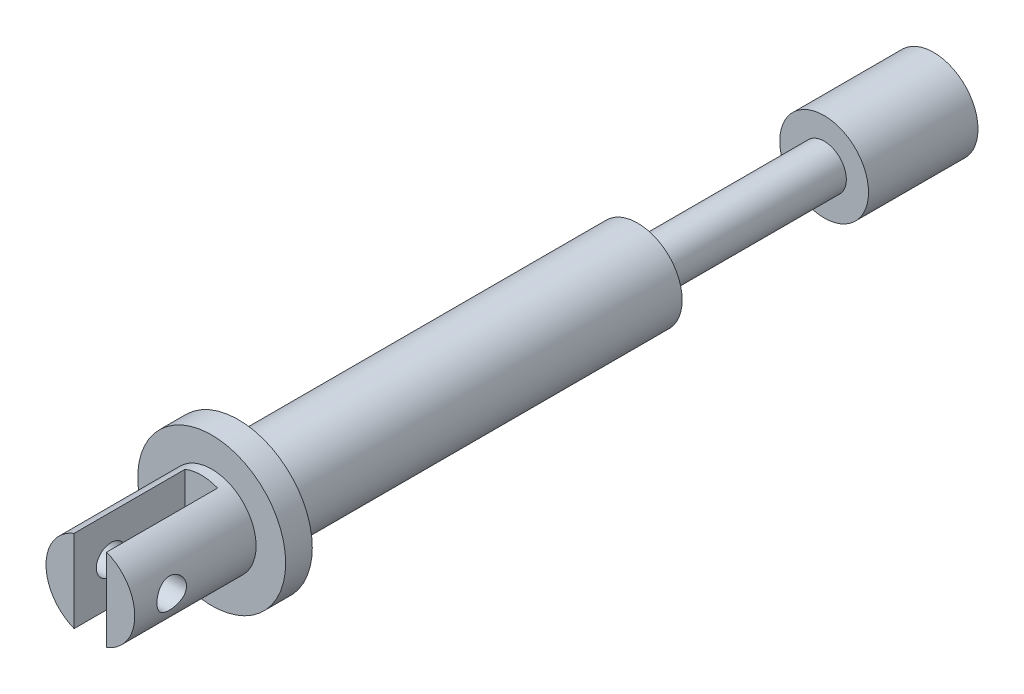
from build123d import *

# Parameters (mm, degrees)
SKETCH1_R               = 1.5
BOSS_EXTRUDE1_DEPTH     = 28.5
SKETCH2_R               = 3
BOSS_EXTRUDE2_DEPTH     = 37
SKETCH5_R               = 5
BOSS_EXTRUDE3_DEPTH     = 1.8
SKETCH6_R               = 3
BOSS_EXTRUDE4_DEPTH     = 7.4
SKETCH3_W               = 2.2
SKETCH3_H               = 7.5
CUT_EXTRUDE1_DEPTH      = 6
CUT_EXTRUDE1_DEPTH_BACK = 6
SKETCH4_R               = 1
CUT_EXTRUDE2_DEPTH      = 6
CUT_EXTRUDE2_DEPTH_BACK = 6


with BuildPart() as part:
    # Sketch1 → Boss-Extrude1 (new body, symmetric)
    with BuildSketch(Plane.XY):
        Circle(SKETCH1_R)
    extrude(amount=BOSS_EXTRUDE1_DEPTH, both=True)

    # Sketch2 → Boss-Extrude2 (add)
    with BuildSketch(Plane.XY.offset(28.5)):
        Circle(SKETCH2_R)
    extrude(amount=-BOSS_EXTRUDE2_DEPTH)

    # Sketch5 → Boss-Extrude3 (add)
    with BuildSketch(Plane.XY.offset(18.5)):
        Circle(SKETCH5_R)
    extrude(amount=BOSS_EXTRUDE3_DEPTH)

    # Sketch6 → Boss-Extrude4 (add)
    with BuildSketch(Plane(origin=(0, 0, -21.1), x_dir=(-1, 0, 0), z_dir=(0, 0, -1))):
        Circle(SKETCH6_R)
    extrude(amount=BOSS_EXTRUDE4_DEPTH)

    # Sketch3 → Cut-Extrude1 (cut, two sides)
    with BuildSketch(Plane(origin=(0, 0, 0), x_dir=(1, 0, 0), z_dir=(0, 1, 0))) as cut_extrude1_sk:
        with Locations((0, -24.75)):
            Rectangle(SKETCH3_W, SKETCH3_H)
    extrude(amount=CUT_EXTRUDE1_DEPTH, mode=Mode.SUBTRACT)
    extrude(cut_extrude1_sk.sketch, amount=-CUT_EXTRUDE1_DEPTH_BACK, mode=Mode.SUBTRACT)

    # Sketch4 → Cut-Extrude2 (cut, two sides)
    with BuildSketch(Plane(origin=(0, 0, 0), x_dir=(0, 0, -1), z_dir=(1, 0, 0))) as cut_extrude2_sk:
        with Locations((-26, 0)):
            Circle(SKETCH4_R)
    extrude(amount=CUT_EXTRUDE2_DEPTH, mode=Mode.SUBTRACT)
    extrude(cut_extrude2_sk.sketch, amount=-CUT_EXTRUDE2_DEPTH_BACK, mode=Mode.SUBTRACT)


solid = part.part
